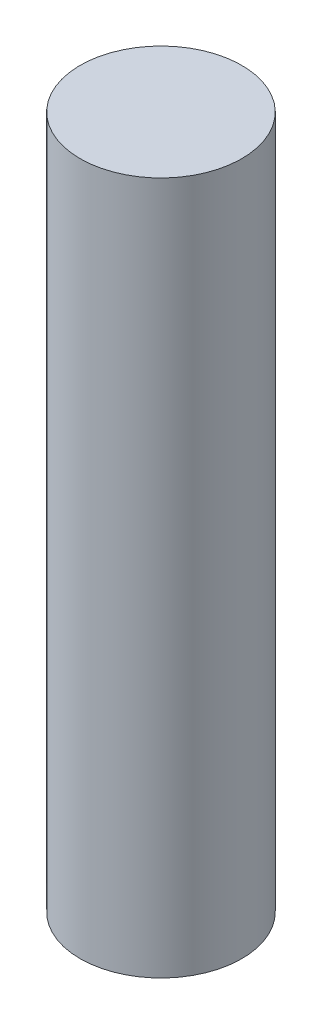
from build123d import *

# Parameters (mm, degrees)
SKETCH1_R           = 3.5
BOSS_EXTRUDE1_DEPTH = 29.999999944
SKETCH2_R           = 2.43
CUT_EXTRUDE1_DEPTH  = 3


with BuildPart() as part:
    # Sketch1 → Boss-Extrude1 (new body)
    with BuildSketch(Plane(origin=(0, 0, 0), x_dir=(1, 0, 0), z_dir=(0, 1, 0))):
        Circle(SKETCH1_R)
    extrude(amount=BOSS_EXTRUDE1_DEPTH)

    # Sketch2 → Cut-Extrude1 (cut)
    with BuildSketch(Plane.XZ):
        Circle(SKETCH2_R)
    extrude(amount=-CUT_EXTRUDE1_DEPTH, mode=Mode.SUBTRACT)


solid = part.part
